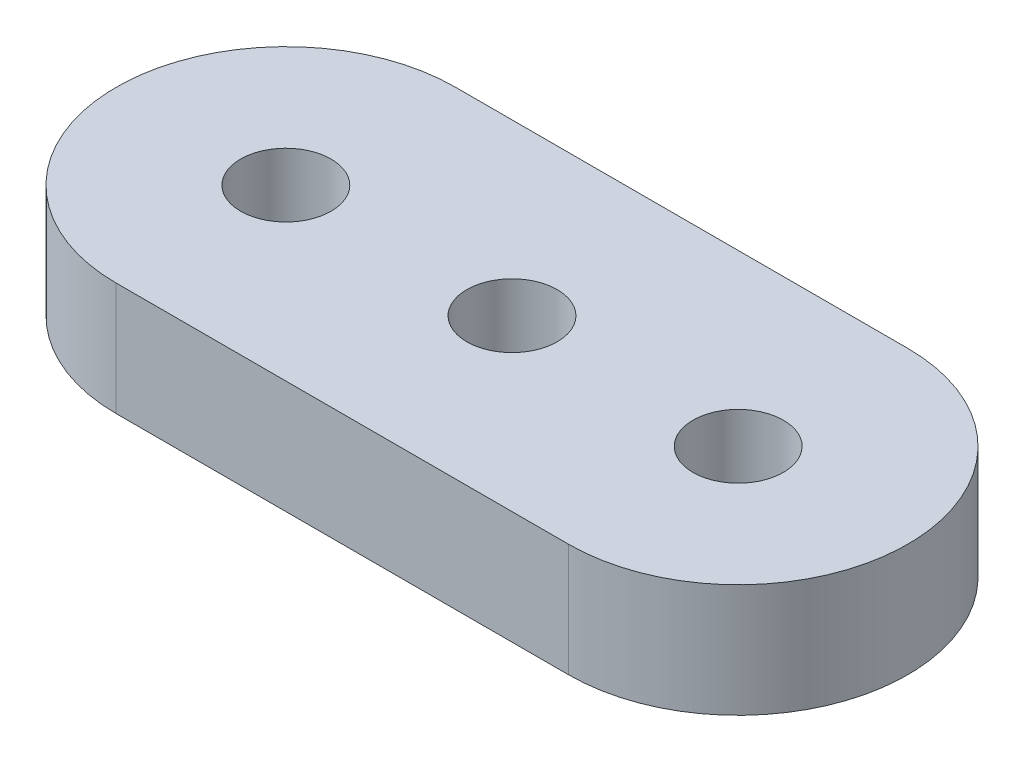
from build123d import *

# Parameters (mm, degrees)
BOSS_EXTRUDE1_DEPTH = 2.54
SKETCH2_R           = 1.016
CUT_EXTRUDE1_DEPTH  = 3.54


with BuildPart() as part:
    # Sketch1 → Boss-Extrude1 (new body)
    with BuildSketch(Plane(origin=(0, 0, 0), x_dir=(1, 0, 0), z_dir=(0, 1, 0))):
        with BuildLine():
            Line((0, 0), (10.16, 0))
            ThreePointArc((10.16, 0), (13.97, 3.81), (10.16, 7.62))
            Line((10.16, 7.62), (0, 7.62))
            ThreePointArc((0, 7.62), (-3.81, 3.81), (0, 0))
        make_face()
    extrude(amount=BOSS_EXTRUDE1_DEPTH)

    # Sketch2 → Cut-Extrude1 (cut, through all)
    with BuildSketch(Plane(origin=(0, 2.54, 0), x_dir=(1, 0, 0), z_dir=(0, 1, 0))):
        with Locations((0, 3.81)):
            Circle(SKETCH2_R)
        with Locations((5.08, 3.81)):
            Circle(SKETCH2_R)
        with Locations((10.16, 3.81)):
            Circle(SKETCH2_R)
    extrude(amount=-CUT_EXTRUDE1_DEPTH, mode=Mode.SUBTRACT)


solid = part.part
